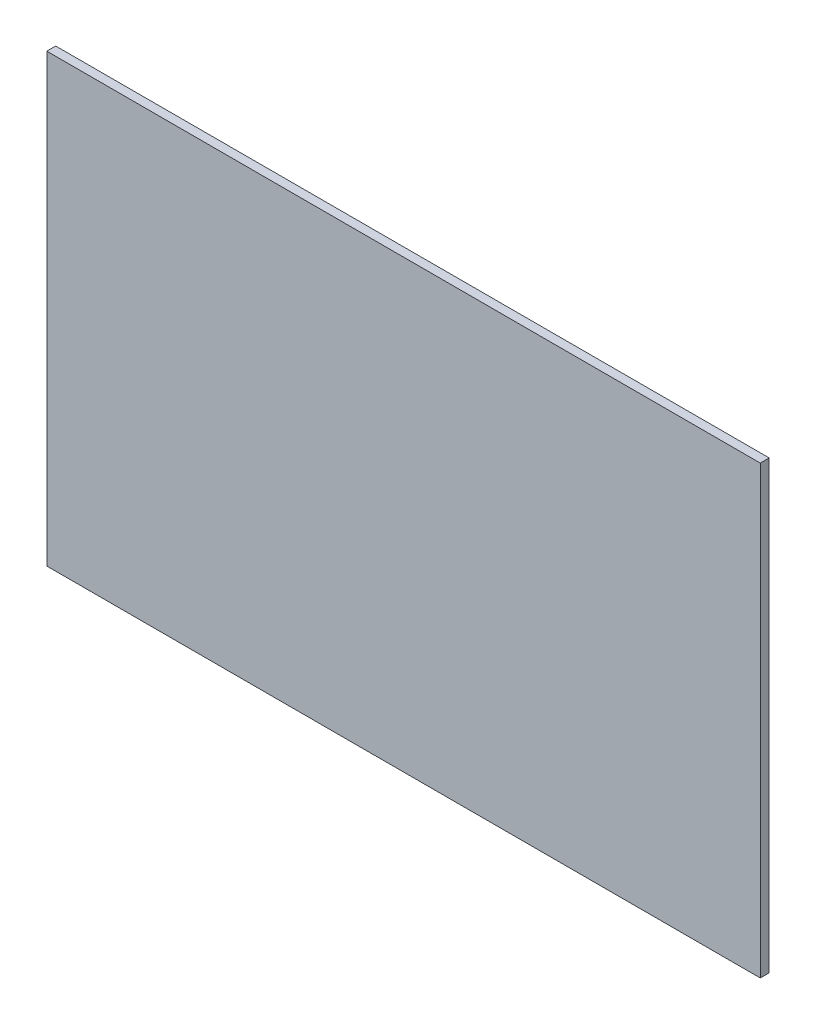
from build123d import *

# Parameters (mm, degrees)
SKETCH1_W           = 800
SKETCH1_H           = 500
BOSS_EXTRUDE1_DEPTH = 10


with BuildPart() as part:
    # Sketch1 → Boss-Extrude1 (new body)
    with BuildSketch(Plane.XY):
        Rectangle(SKETCH1_W, SKETCH1_H)
    extrude(amount=BOSS_EXTRUDE1_DEPTH)


solid = part.part
